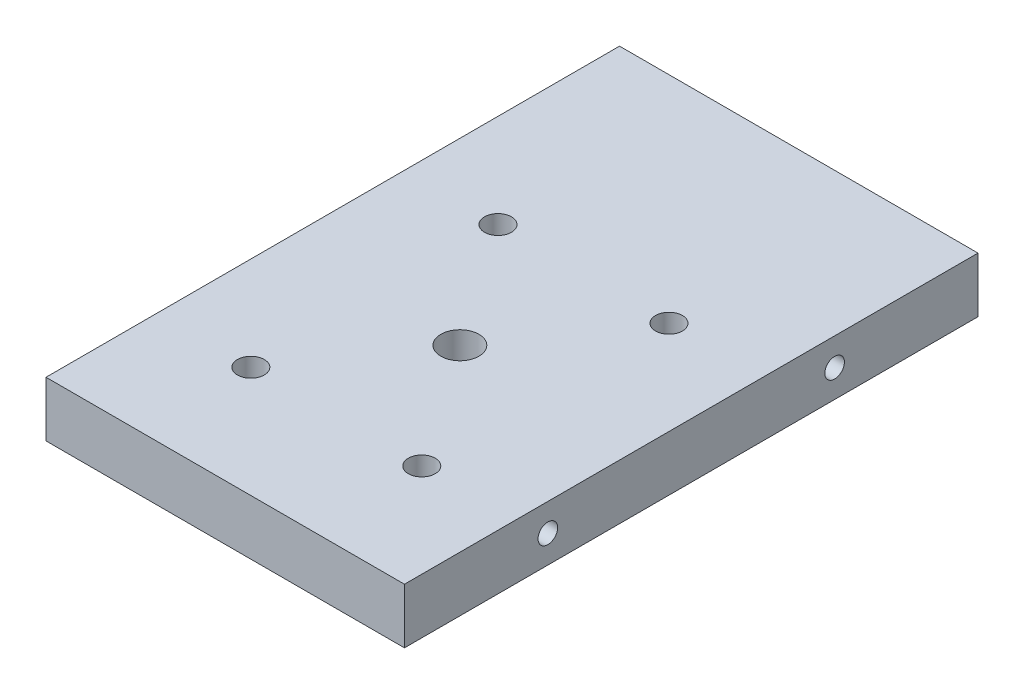
from build123d import *

# Parameters (mm, degrees)
SKETCH1_W                 = 32.5
SKETCH1_H                 = 52
BOSS_EXTRUDE1_DEPTH       = 5
F_2_56_TAPPED_HOLE1_D     = 1.778
F_2_56_TAPPED_HOLE1_DEPTH = 7.46583491
F_2_56_TAPPED_HOLE1_TIP   = 0.53416509
F_2_56_TAPPED_HOLE2_D     = 1.778
F_2_56_TAPPED_HOLE2_DEPTH = 7.46583491
F_2_56_TAPPED_HOLE2_TIP   = 0.53416509
F_8_32_TAPPED_HOLE1_D     = 3.4544
F_8_32_TAPPED_HOLE1_DEPTH = 9.672193539
F_8_32_TAPPED_HOLE1_TIP   = 1.037806461
SKETCH16_R                = 1.22
CUT_EXTRUDE4_DEPTH        = 5


with BuildPart() as part:
    # Sketch1 → Boss-Extrude1 (new body)
    with BuildSketch(Plane(origin=(0, 0, 0), x_dir=(1, 0, 0), z_dir=(0, 1, 0))):
        with Locations((16.25, 26)):
            Rectangle(SKETCH1_W, SKETCH1_H)
    extrude(amount=BOSS_EXTRUDE1_DEPTH)

    # #2-56 Tapped Hole1
    with Locations(Plane.ZY):
        with Locations((-39, 2.5), (-13, 2.5)):
            Hole(F_2_56_TAPPED_HOLE1_D / 2, depth=F_2_56_TAPPED_HOLE1_DEPTH)
            with Locations((0, 0, -(F_2_56_TAPPED_HOLE1_DEPTH + F_2_56_TAPPED_HOLE1_TIP / 2))):  # 118° drill point
                Cone(0, F_2_56_TAPPED_HOLE1_D / 2, F_2_56_TAPPED_HOLE1_TIP, mode=Mode.SUBTRACT)

    # #2-56 Tapped Hole2
    with Locations(Plane(origin=(32.5, 0, 0), x_dir=(0, 0, -1), z_dir=(1, 0, 0))):
        with Locations((13, 2.5), (39, 2.5)):
            Hole(F_2_56_TAPPED_HOLE2_D / 2, depth=F_2_56_TAPPED_HOLE2_DEPTH)
            with Locations((0, 0, -(F_2_56_TAPPED_HOLE2_DEPTH + F_2_56_TAPPED_HOLE2_TIP / 2))):  # 118° drill point
                Cone(0, F_2_56_TAPPED_HOLE2_D / 2, F_2_56_TAPPED_HOLE2_TIP, mode=Mode.SUBTRACT)

    # #8-32 Tapped Hole1
    with Locations(Plane(origin=(0, 5, 0), x_dir=(1, 0, 0), z_dir=(0, 1, 0))):
        with Locations((16.25, 21.275)):
            Hole(F_8_32_TAPPED_HOLE1_D / 2, depth=F_8_32_TAPPED_HOLE1_DEPTH)
            with Locations((0, 0, -(F_8_32_TAPPED_HOLE1_DEPTH + F_8_32_TAPPED_HOLE1_TIP / 2))):  # 118° drill point
                Cone(0, F_8_32_TAPPED_HOLE1_D / 2, F_8_32_TAPPED_HOLE1_TIP, mode=Mode.SUBTRACT)

    # Sketch16 → Cut-Extrude4 (cut)
    with BuildSketch(Plane(origin=(0, 5, 0), x_dir=(1, 0, 0), z_dir=(0, 1, 0))):
        with Locations((8.5, 32.48)):
            Circle(SKETCH16_R)
        with Locations((24, 32.48)):
            Circle(SKETCH16_R)
        with Locations((8.5, 10.07)):
            Circle(SKETCH16_R)
        with Locations((24, 10.07)):
            Circle(SKETCH16_R)
    extrude(amount=-CUT_EXTRUDE4_DEPTH, mode=Mode.SUBTRACT)


solid = part.part
